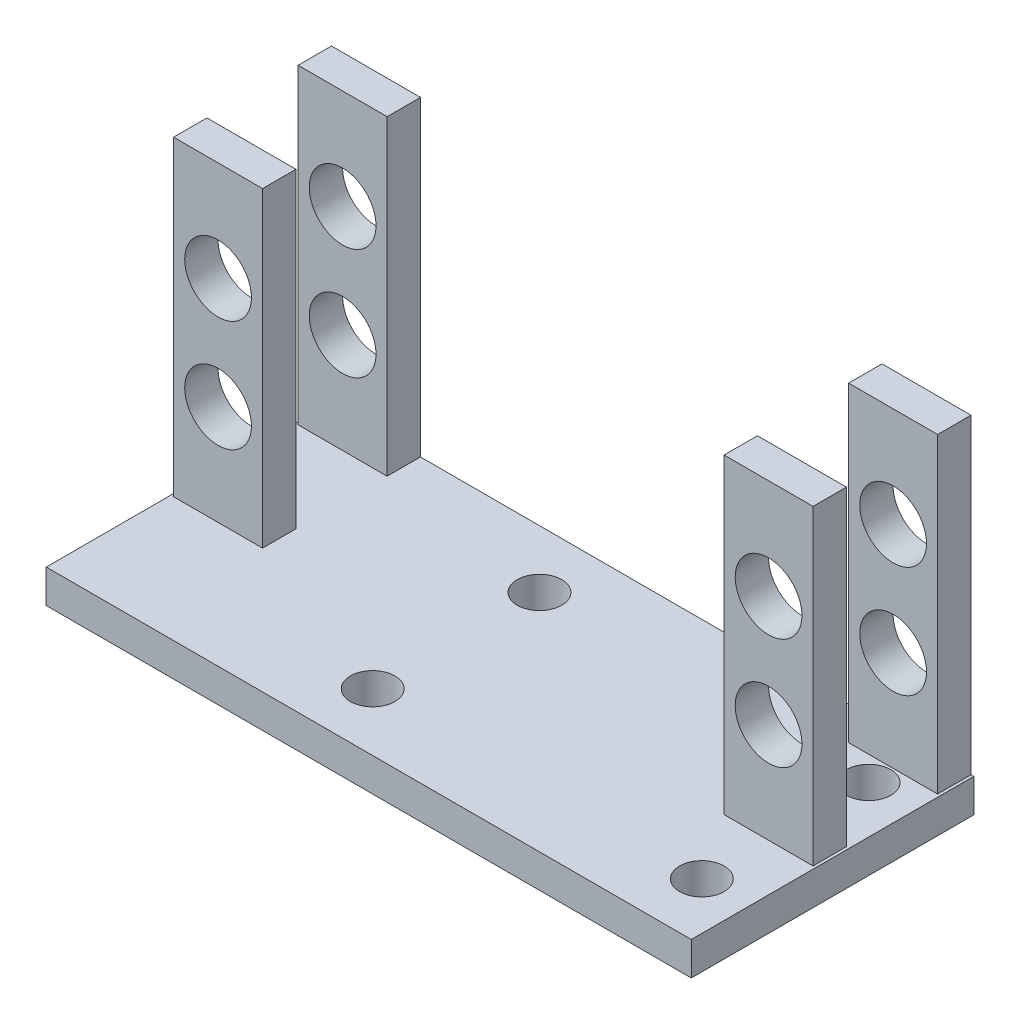
from build123d import *

# Parameters (mm, degrees)
SKETCH_1_W          = 58
SKETCH_1_H          = 25.4
EXTRUDE_1_DEPTH     = 3
SKETCH_2_W          = 8
SKETCH_2_H          = 3
EXTRUDE_2_DEPTH     = 28
SKETCH_3_R          = 3
CUT_EXTRUDE_1_DEPTH = 12
SKETCH_4_R          = 2
CUT_EXTRUDE_2_DEPTH = 22


with BuildPart() as part:
    # 草图1 → 凸台-拉伸1 (new body)
    with BuildSketch(Plane(origin=(0, 0, 0), x_dir=(1, 0, 0), z_dir=(0, 1, 0))):
        Rectangle(SKETCH_1_W, SKETCH_1_H)
    extrude(amount=EXTRUDE_1_DEPTH)

    # 草图2 → 凸台-拉伸2 (add)
    with BuildSketch(Plane(origin=(0, 3, 0), x_dir=(1, 0, 0), z_dir=(0, 1, 0))):
        with Locations((-24.75, 11.2)):
            Rectangle(SKETCH_2_W, SKETCH_2_H)
        with Locations((24.75, 11.2)):
            Rectangle(SKETCH_2_W, SKETCH_2_H)
        with Locations((-24.75, 0)):
            Rectangle(SKETCH_2_W, SKETCH_2_H)
        with Locations((24.75, 0)):
            Rectangle(SKETCH_2_W, SKETCH_2_H)
    extrude(amount=EXTRUDE_2_DEPTH)

    # 草图3 → 切除-拉伸1 (cut, symmetric)
    with BuildSketch(Plane.XY.offset(-9.7)):
        with Locations((-24.75, 12)):
            Circle(SKETCH_3_R)
        with Locations((-24.75, 22)):
            Circle(SKETCH_3_R)
        with Locations((24.75, 12)):
            Circle(SKETCH_3_R)
        with Locations((24.75, 22)):
            Circle(SKETCH_3_R)
    extrude(amount=CUT_EXTRUDE_1_DEPTH, both=True, mode=Mode.SUBTRACT)

    # 草图4 → 切除-拉伸2 (cut)
    with BuildSketch(Plane(origin=(0, 3, 0), x_dir=(1, 0, 0), z_dir=(0, 1, 0))):
        with Locations((24.75, -7.5)):
            Circle(SKETCH_4_R)
        with Locations((24.75, 7.5)):
            Circle(SKETCH_4_R)
        with Locations((-4.85, 7.5)):
            Circle(SKETCH_4_R)
        with Locations((-4.85, -7.5)):
            Circle(SKETCH_4_R)
    extrude(amount=-CUT_EXTRUDE_2_DEPTH, mode=Mode.SUBTRACT)


solid = part.part
